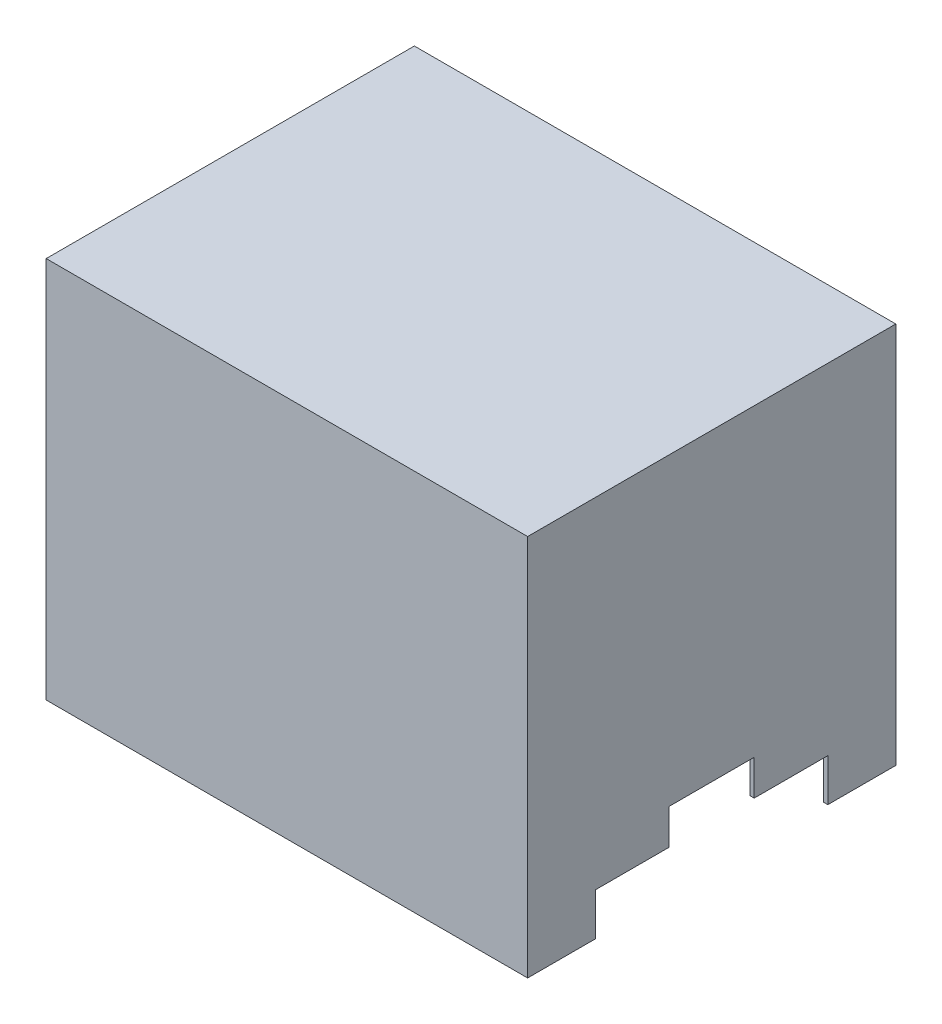
from build123d import *

# Parameters (mm, degrees)
CROQUIS1_W              = 340
CROQUIS1_H              = 260
SALIENTE_EXTRUIR1_DEPTH = 270
CROQUIS2_W              = 334
CROQUIS2_H              = 254
CORTAR_EXTRUIR1_DEPTH   = 267
CORTAR_EXTRUIR2_DEPTH   = 341


with BuildPart() as part:
    # Croquis1 → Saliente-Extruir1 (new body)
    with BuildSketch(Plane(origin=(0, 0, 0), x_dir=(1, 0, 0), z_dir=(0, 1, 0))):
        Rectangle(CROQUIS1_W, CROQUIS1_H)
    extrude(amount=SALIENTE_EXTRUIR1_DEPTH)

    # Croquis2 → Cortar-Extruir1 (cut)
    with BuildSketch(Plane.XZ):
        Rectangle(CROQUIS2_W, CROQUIS2_H)
    extrude(amount=-CORTAR_EXTRUIR1_DEPTH, mode=Mode.SUBTRACT)

    # Croquis3 → Cortar-Extruir2 (cut, through all)
    with BuildSketch(Plane(origin=(170, 0, 0), x_dir=(0, 0, -1), z_dir=(1, 0, 0))):
        Polygon((0, 0), (-82, 0), (-82, 30), (-30, 30), (-30, 55), (30, 55), (30, 30), (82, 30), (82, 0), align=None)
    extrude(amount=-CORTAR_EXTRUIR2_DEPTH, mode=Mode.SUBTRACT)


solid = part.part
